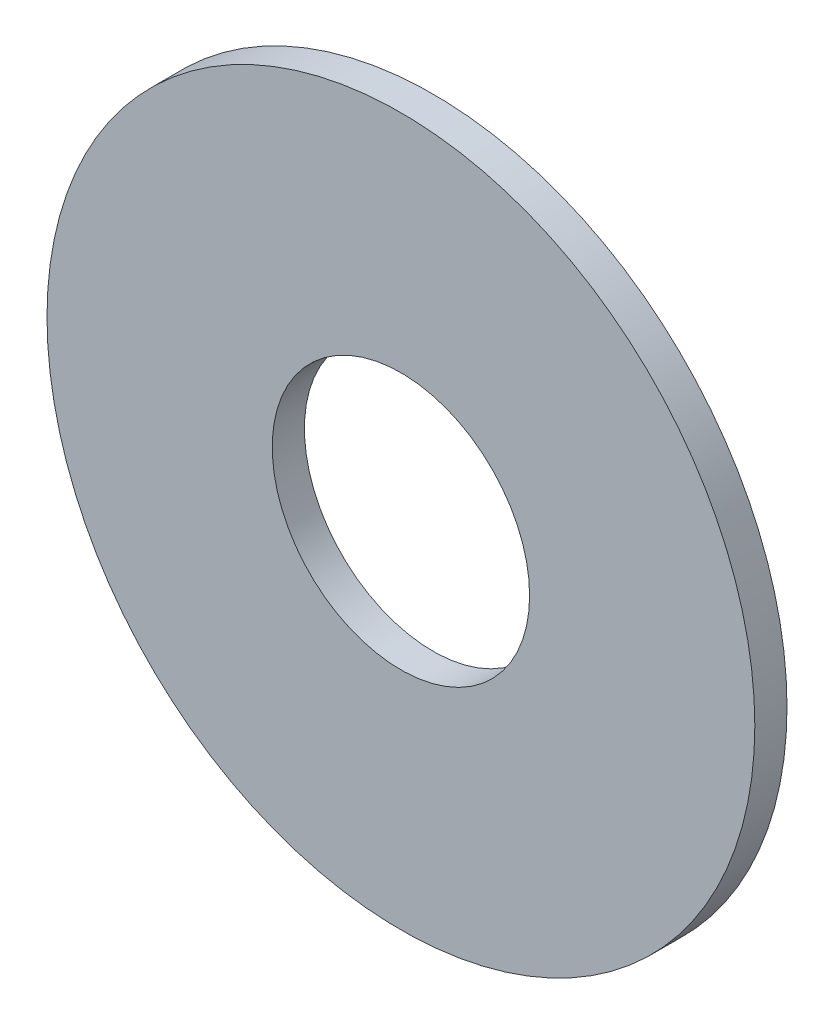
from build123d import *

# Parameters (mm, degrees)
ESQUISSE1_R      = 5.5
ESQUISSE1_R_2    = 2
EXTRUSION1_DEPTH = 0.5


with BuildPart() as part:
    # Esquisse1 → Extrusion1 (new body)
    with BuildSketch(Plane.XY):
        Circle(ESQUISSE1_R)
        Circle(ESQUISSE1_R_2, mode=Mode.SUBTRACT)
    extrude(amount=EXTRUSION1_DEPTH)


solid = part.part
